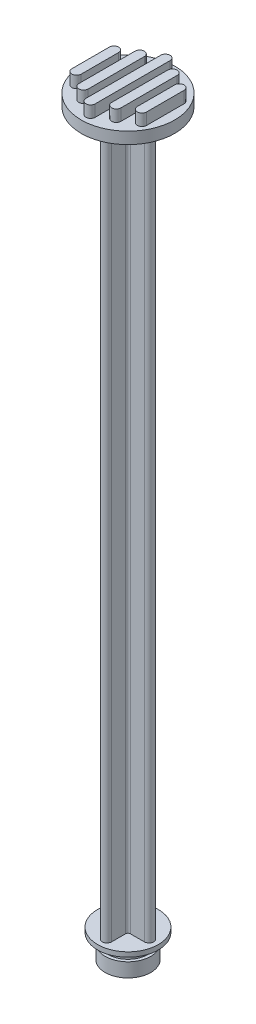
from build123d import *

# Parameters (mm, degrees)
BOSS_EXTRUDE1_DEPTH = 152
SKETCH3_R           = 10
BOSS_EXTRUDE2_DEPTH = 2.5
BOSS_EXTRUDE3_DEPTH = 2.5


with BuildPart() as part:
    # Sketch1 → Revolve1 (revolve)
    with BuildSketch(Plane.XY):
        Polygon((0, 0), (4.875, 0), (4.875, 3), (4.225, 3), (4.225, 5), (6.5, 5), (6.5, 6), (0, 6), align=None)
    revolve(axis=Axis((0, 6, 0), (0, -1, 0)))

    # Sketch2 → Boss-Extrude1 (add)
    with BuildSketch(Plane(origin=(0, 6, 0), x_dir=(1, 0, 0), z_dir=(0, 1, 0))):
        with BuildLine():
            Line((-1, 4.5), (-1, 1.5))
            ThreePointArc((-1, 1.5), (-1.146446609, 1.146446609), (-1.5, 1))
            Line((-1.5, 1), (-4.5, 1))
            ThreePointArc((-4.5, 1), (-5.5, 0), (-4.5, -1))
            Line((-4.5, -1), (-1.5, -1))
            ThreePointArc((-1.5, -1), (-1.146446609, -1.146446609), (-1, -1.5))
            Line((-1, -1.5), (-1, -4.5))
            ThreePointArc((-1, -4.5), (0, -5.5), (1, -4.5))
            Line((1, -4.5), (1, -1.5))
            ThreePointArc((1, -1.5), (1.146446609, -1.146446609), (1.5, -1))
            Line((1.5, -1), (4.5, -1))
            ThreePointArc((4.5, -1), (5.5, 0), (4.5, 1))
            Line((4.5, 1), (1.5, 1))
            ThreePointArc((1.5, 1), (1.146446609, 1.146446609), (1, 1.5))
            Line((1, 1.5), (1, 4.5))
            ThreePointArc((1, 4.5), (0, 5.5), (-1, 4.5))
        make_face()
    extrude(amount=BOSS_EXTRUDE1_DEPTH)

    # Sketch3 → Boss-Extrude2 (add)
    with BuildSketch(Plane(origin=(0, 158, 0), x_dir=(1, 0, 0), z_dir=(0, 1, 0))):
        Circle(SKETCH3_R)
    extrude(amount=BOSS_EXTRUDE2_DEPTH)

    # Sketch4 → Boss-Extrude3 (add)
    with BuildSketch(Plane(origin=(0, 160.5, 0), x_dir=(1, 0, 0), z_dir=(0, 1, 0))):
        with BuildLine():
            ThreePointArc((1, 8), (0, 9), (-1, 8))
            Line((-1, 8), (-1, -8))
            ThreePointArc((-1, -8), (0, -9), (1, -8))
            Line((1, -8), (1, 8))
        make_face()
        with BuildLine():
            ThreePointArc((-2.5, 6), (-3.5, 7), (-4.5, 6))
            Line((-4.5, 6), (-4.5, -6))
            ThreePointArc((-4.5, -6), (-3.5, -7), (-2.5, -6))
            Line((-2.5, -6), (-2.5, 6))
        make_face()
        with BuildLine():
            ThreePointArc((4.5, 6), (3.5, 7), (2.5, 6))
            Line((2.5, 6), (2.5, -6))
            ThreePointArc((2.5, -6), (3.5, -7), (4.5, -6))
            Line((4.5, -6), (4.5, 6))
        make_face()
        with BuildLine():
            ThreePointArc((6, 4), (7, 5), (8, 4))
            Line((8, 4), (8, -4))
            ThreePointArc((8, -4), (7, -5), (6, -4))
            Line((6, -4), (6, 4))
        make_face()
        with BuildLine():
            Line((-6, -4), (-6, 4))
            ThreePointArc((-6, 4), (-7, 5), (-8, 4))
            Line((-8, 4), (-8, -4))
            ThreePointArc((-8, -4), (-7, -5), (-6, -4))
        make_face()
    extrude(amount=BOSS_EXTRUDE3_DEPTH)


solid = part.part
